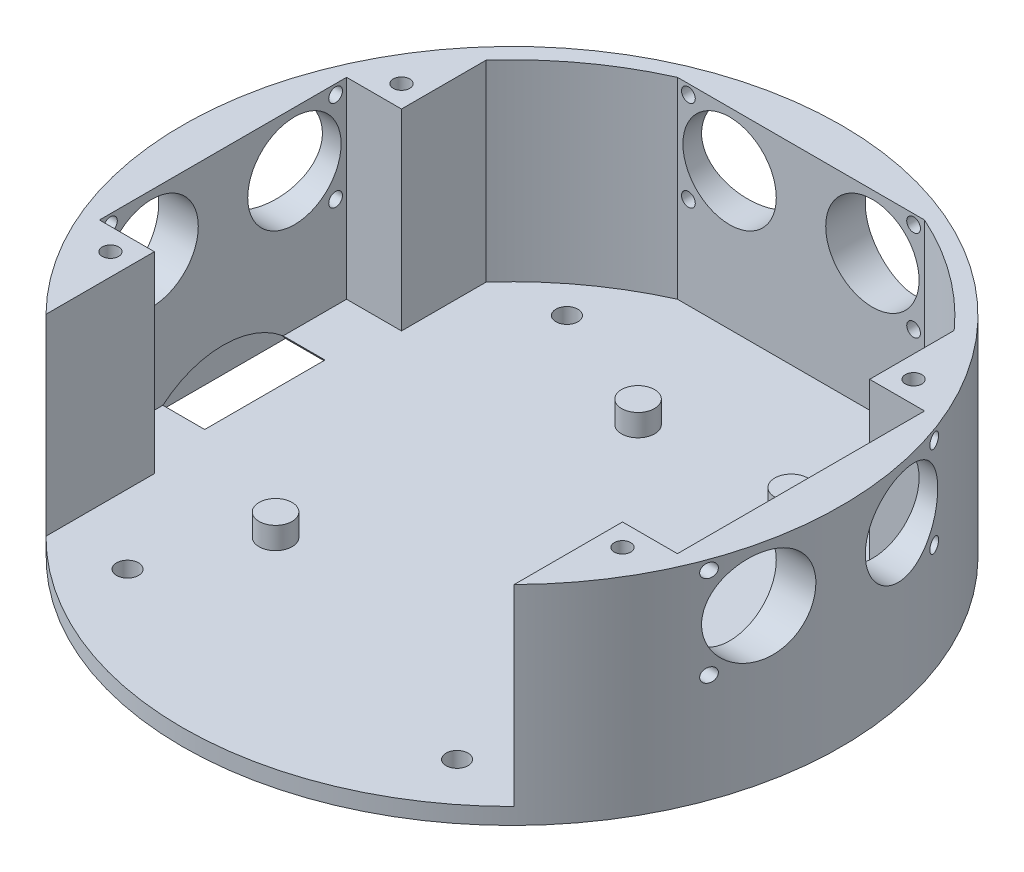
from build123d import *

# Parameters (mm, degrees)
SKETCH1_R                       = 60
BOSS_EXTRUDE1_DEPTH             = 3
SKETCH2_R                       = 3
BOSS_EXTRUDE2_DEPTH             = 4
BOSS_EXTRUDE3_DEPTH             = 35
CUT_EXTRUDE1_START              = -8.378511347
SKETCH4_R                       = 8.5
SKETCH4_R_2                     = 1.25
CUT_EXTRUDE1_DEPTH              = 122
CIRPATTERN1_COUNT               = 2
CIRPATTERN1_ANGLE               = 90
CIRPATTERN1_THE_OTHER_WAY_COUNT = 2
CIRPATTERN1_THE_OTHER_WAY_ANGLE = 90
SKETCH5_R                       = 2
CUT_EXTRUDE2_DEPTH              = 36.0000001
CUT_EXTRUDE2_DEPTH_BACK         = 4.0000001
SKETCH7_R                       = 17
CUT_EXTRUDE3_DEPTH              = 10
BOSS_EXTRUDE4_DEPTH             = 35
SKETCH9_R                       = 1.5
CUT_EXTRUDE4_DEPTH              = 35


with BuildPart() as part:
    # Sketch1 → Boss-Extrude1 (new body)
    with BuildSketch(Plane(origin=(0, 0, 0), x_dir=(1, 0, 0), z_dir=(0, 1, 0))):
        Circle(SKETCH1_R)
    extrude(amount=BOSS_EXTRUDE1_DEPTH)

    # Sketch2 → Boss-Extrude2 (add)
    with BuildSketch(Plane(origin=(0, 3, 0), x_dir=(1, 0, 0), z_dir=(0, 1, 0))):
        with Locations((-6.35, 29.3)):
            Circle(SKETCH2_R)
        with Locations((21.55, 29.3)):
            Circle(SKETCH2_R)
        with Locations((-21.55, -21.5)):
            Circle(SKETCH2_R)
    extrude(amount=BOSS_EXTRUDE2_DEPTH)

    # Sketch3 → Boss-Extrude3 (add)
    with BuildSketch(Plane(origin=(0, 3, 0), x_dir=(1, 0, 0), z_dir=(0, 1, 0))):
        with BuildLine():
            Line((-22.5, 55.621488653), (-22.5, 52.621488653))
            Line((-22.5, 52.621488653), (22.5, 52.621488653))
            Line((22.5, 52.621488653), (22.5, 55.621488653))
            ThreePointArc((22.5, 55.621488653), (0, 60), (-22.5, 55.621488653))
        make_face()
    boss_extrude3 = extrude(amount=BOSS_EXTRUDE3_DEPTH)

    # Sketch4 → Cut-Extrude1 (cut)
    with BuildSketch(Plane.XY.offset(-52.621488653).offset(CUT_EXTRUDE1_START)):
        with Locations((-13, 28)):
            Circle(SKETCH4_R)
        with Locations((13, 28)):
            Circle(SKETCH4_R)
        with Locations((-20.5, 19.75)):
            Circle(SKETCH4_R_2)
        with Locations((20.5, 36.25)):
            Circle(SKETCH4_R_2)
        with Locations((-20.5, 36.25)):
            Circle(SKETCH4_R_2)
        with Locations((20.5, 19.75)):
            Circle(SKETCH4_R_2)
    cut_extrude1 = extrude(amount=CUT_EXTRUDE1_DEPTH, mode=Mode.SUBTRACT)

    # CirPattern1: Boss-Extrude3, Cut-Extrude1 ×2 about axis
    cirpattern1_axis = Axis((0, 0, 0), (0, 1, 0))
    for i in range(1, CIRPATTERN1_COUNT):
        add(boss_extrude3.rotate(cirpattern1_axis, i * CIRPATTERN1_ANGLE / (CIRPATTERN1_COUNT - 1)))
        add(cut_extrude1.rotate(cirpattern1_axis, i * CIRPATTERN1_ANGLE / (CIRPATTERN1_COUNT - 1)), mode=Mode.SUBTRACT)

    # CirPattern1 the other way: Boss-Extrude3, Cut-Extrude1 ×2 about axis
    cirpattern1_the_other_way_axis = Axis((0, 0, 0), (0, -1, 0))
    for i in range(1, CIRPATTERN1_THE_OTHER_WAY_COUNT):
        add(boss_extrude3.rotate(cirpattern1_the_other_way_axis, i * CIRPATTERN1_THE_OTHER_WAY_ANGLE / (CIRPATTERN1_THE_OTHER_WAY_COUNT - 1)))
        add(cut_extrude1.rotate(cirpattern1_the_other_way_axis, i * CIRPATTERN1_THE_OTHER_WAY_ANGLE / (CIRPATTERN1_THE_OTHER_WAY_COUNT - 1)), mode=Mode.SUBTRACT)

    # Sketch5 → Cut-Extrude2 (cut, two sides)
    with BuildSketch(Plane(origin=(0, 3, 0), x_dir=(1, 0, 0), z_dir=(0, 1, 0))) as cut_extrude2_sk:
        with Locations((-30, 40)):
            Circle(SKETCH5_R)
        with Locations((30, 40)):
            Circle(SKETCH5_R)
        with Locations((30, -40)):
            Circle(SKETCH5_R)
        with Locations((-30, -40)):
            Circle(SKETCH5_R)
    extrude(amount=CUT_EXTRUDE2_DEPTH, mode=Mode.SUBTRACT)
    extrude(cut_extrude2_sk.sketch, amount=-CUT_EXTRUDE2_DEPTH_BACK, mode=Mode.SUBTRACT)

    # Sketch7 → Cut-Extrude3 (cut)
    with BuildSketch(Plane.ZY.offset(55)):
        with Locations((0, -10)):
            Circle(SKETCH7_R)
    cut_extrude3 = extrude(amount=-CUT_EXTRUDE3_DEPTH, mode=Mode.SUBTRACT)

    # Mirror1: Cut-Extrude3 across plane
    add(cut_extrude3.mirror(Plane(origin=(0, 0, 0), x_dir=(0, 0, 1), z_dir=(1, 0, 0))), mode=Mode.SUBTRACT)

    # Sketch8 → Boss-Extrude4 (add)
    with BuildSketch(Plane(origin=(0, 3, 0), x_dir=(1, 0, 0), z_dir=(0, 1, 0))):
        with BuildLine():
            Line((-55.621488653, 22.5), (-52.621488653, 22.5))
            Line((-52.621488653, 22.5), (-42.621488653, 22.5))
            Line((-42.621488653, 22.5), (-42.621488653, 37.894532881))
            ThreePointArc((-42.621488653, 37.894532881), (-33.33422239, 46.314816417), (-22.5, 52.621488653))
            Line((-22.5, 52.621488653), (-22.5, 55.621488653))
            ThreePointArc((-22.5, 55.621488653), (-42.426406871, 42.426406871), (-55.621488653, 22.5))
        make_face()
        with BuildLine():
            Line((55.621488653, 22.5), (52.621488653, 22.5))
            Line((52.621488653, 22.5), (42.621488653, 22.5))
            Line((42.621488653, 22.5), (42.621488653, 37.894532881))
            ThreePointArc((42.621488653, 37.894532881), (33.33422239, 46.314816417), (22.5, 52.621488653))
            Line((22.5, 52.621488653), (22.5, 55.621488653))
            ThreePointArc((22.5, 55.621488653), (42.426406871, 42.426406871), (55.621488653, 22.5))
        make_face()
        with BuildLine():
            Line((-55.621488653, -22.5), (-42.621488653, -22.5))
            Line((-42.621488653, -22.5), (-42.621488653, -42.230423926))
            ThreePointArc((-42.621488653, -42.230423926), (-50.10232584, -33.011466878), (-55.621488653, -22.5))
        make_face()
        with BuildLine():
            Line((55.621488653, -22.5), (42.621488653, -22.5))
            Line((42.621488653, -22.5), (42.621488653, -42.230423926))
            ThreePointArc((42.621488653, -42.230423926), (50.10232584, -33.011466878), (55.621488653, -22.5))
        make_face()
    extrude(amount=BOSS_EXTRUDE4_DEPTH)

    # Sketch9 → Cut-Extrude4 (cut)
    with BuildSketch(Plane(origin=(0, 38, 0), x_dir=(1, 0, 0), z_dir=(0, 1, 0))):
        with Locations((-46.621488653, 26.5)):
            Circle(SKETCH9_R)
        with Locations((-46.621488653, -26.5)):
            Circle(SKETCH9_R)
        with Locations((46.621488653, -26.5)):
            Circle(SKETCH9_R)
        with Locations((46.621488653, 26.5)):
            Circle(SKETCH9_R)
    extrude(amount=-CUT_EXTRUDE4_DEPTH, mode=Mode.SUBTRACT)


solid = part.part
